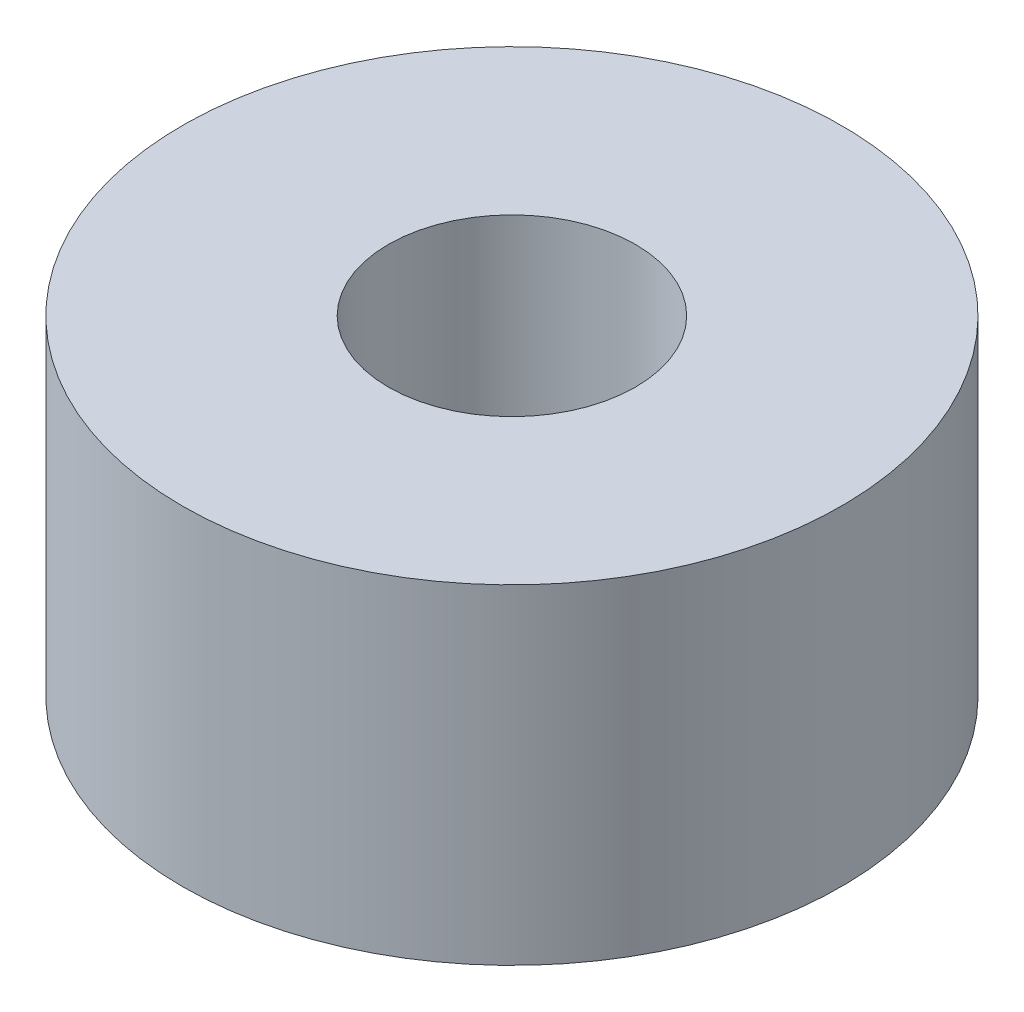
from build123d import *

# Parameters (mm, degrees)
SKETCH1_R               = 10
BOSS_EXTRUDE1_DEPTH     = 10
SKETCH2_R               = 3.75
CUT_EXTRUDE1_DEPTH      = 1
CUT_EXTRUDE1_DEPTH_BACK = 11


with BuildPart() as part:
    # Sketch1 → Boss-Extrude1 (new body)
    with BuildSketch(Plane(origin=(0, 0, 0), x_dir=(1, 0, 0), z_dir=(0, 1, 0))):
        Circle(SKETCH1_R)
    extrude(amount=BOSS_EXTRUDE1_DEPTH)

    # Sketch2 → Cut-Extrude1 (cut, two sides)
    with BuildSketch(Plane(origin=(0, 10, 0), x_dir=(1, 0, 0), z_dir=(0, 1, 0))) as cut_extrude1_sk:
        Circle(SKETCH2_R)
    extrude(amount=CUT_EXTRUDE1_DEPTH, mode=Mode.SUBTRACT)
    extrude(cut_extrude1_sk.sketch, amount=-CUT_EXTRUDE1_DEPTH_BACK, mode=Mode.SUBTRACT)


solid = part.part
